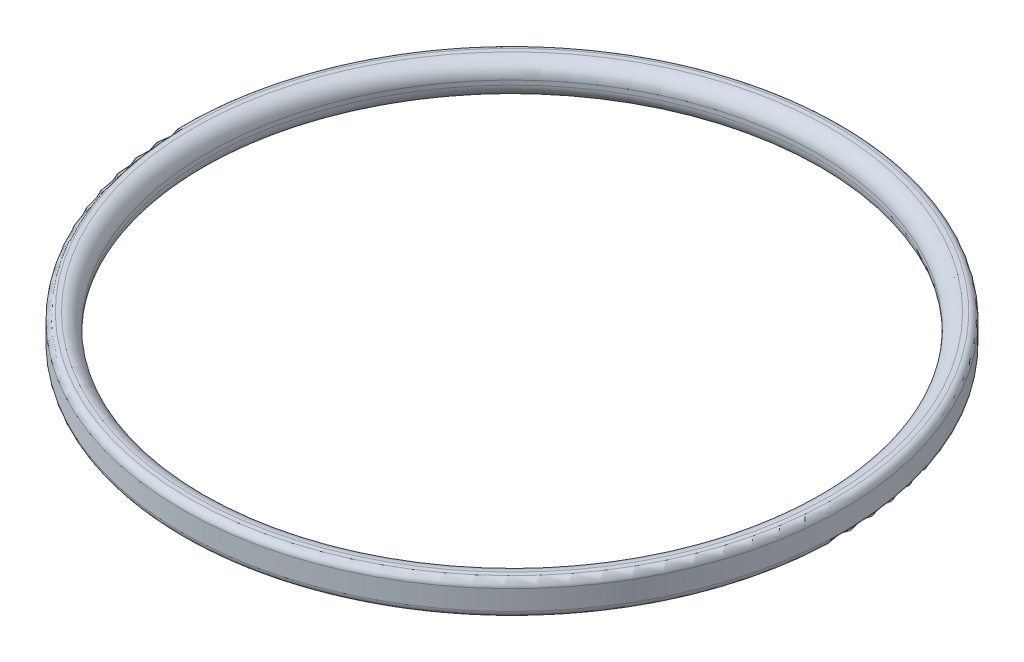
from build123d import *

# Parameters (mm, degrees)
SKETCH2_W = 2.921
SKETCH2_H = 3.81
FILLET1_R = 1.651
FILLET3_R = 0.762


with BuildPart() as part:
    # Sketch2 → Revolve1 (revolve)
    with BuildSketch(Plane.XY):
        with Locations((36.6395, 1.905)):
            Rectangle(SKETCH2_W, SKETCH2_H)
    revolve(axis=Axis((0, -55, 0), (0, 1, 0)))

    # Fillet1
    fillet1_edges = [part.edges().sort_by_distance(p)[0] for p in [
        (-35.179, 3.81, 0),
        (-35.179, 0, 0),
    ]]
    fillet(fillet1_edges, radius=FILLET1_R)

    # Fillet3
    fillet3_edges = [part.edges().sort_by_distance(p)[0] for p in [
        (-38.1, 3.81, 0),
        (-38.1, 0, 0),
    ]]
    fillet(fillet3_edges, radius=FILLET3_R)


solid = part.part
